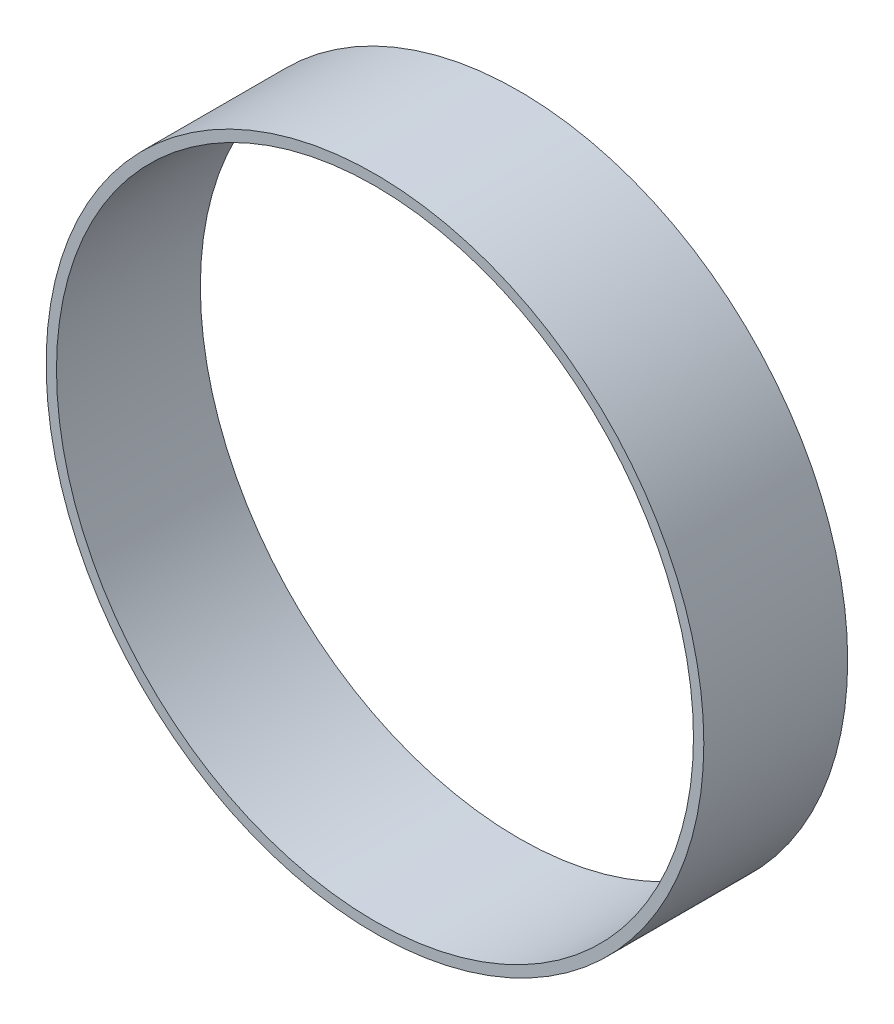
from build123d import *

# Parameters (mm, degrees)
SKETCH2_R      = 101.6
SKETCH2_R_2    = 98.3996
EXTRUDE1_DEPTH = 44.45


with BuildPart() as part:
    # Sketch2 → Extrude1 (new body)
    with BuildSketch(Plane.XY.offset(373.3022368)):
        Circle(SKETCH2_R)
        Circle(SKETCH2_R_2, mode=Mode.SUBTRACT)
    extrude(amount=-EXTRUDE1_DEPTH)


solid = part.part
